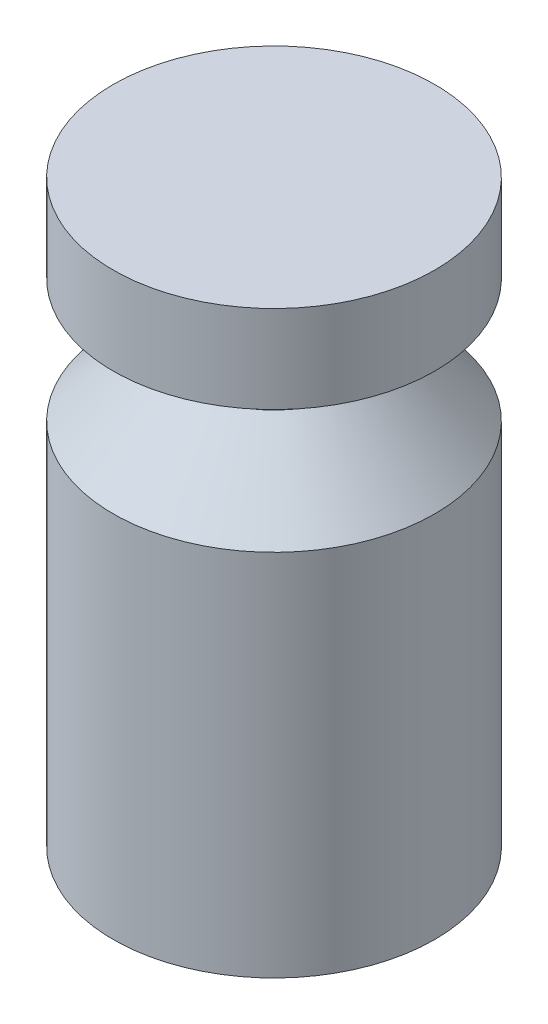
from build123d import *


with BuildPart() as part:
    # Sketch1 → Revolve1 (revolve)
    with BuildSketch(Plane.XY):
        Polygon((0, 0), (14.697828263, 0), (14.697828263, 33.7), (8.25, 40.4), (8.25, 45), (14.697828263, 45), (14.697828263, 53), (0, 53), align=None)
    revolve(axis=Axis((0, 53, 0), (0, -1, 0)))


solid = part.part
